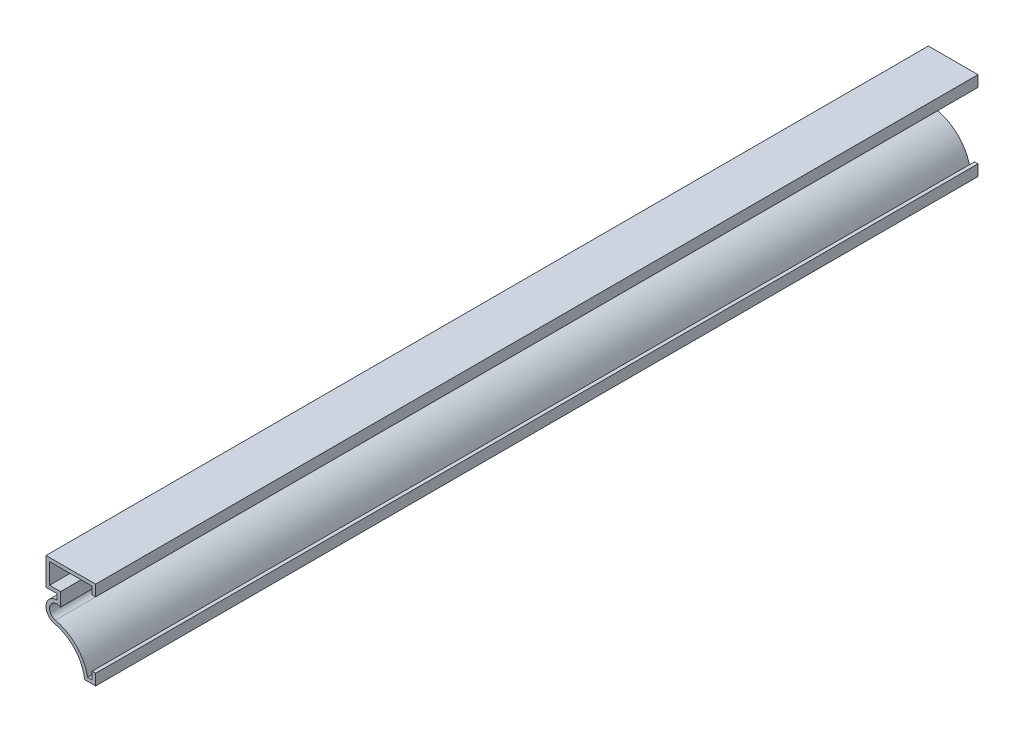
from build123d import *

# Parameters (mm, degrees)
EXTRUDE_THIN1_DEPTH = 254


with BuildPart() as part:
    # Sketch1 → Extrude-Thin1 (new body)
    with BuildSketch(Plane.XY):
        with BuildLine():
            Line((0, 22.225), (0, 25.4))
            Line((0, 25.4), (-14.2875, 25.4))
            Line((-14.2875, 25.4), (-14.2875, 17.4625))
            Line((-14.2875, 17.4625), (-11.1125, 17.4625))
            Line((-11.1125, 17.4625), (-11.1125, 15.875))
            ThreePointArc((-11.1125, 15.875), (-14.26780648, 13.053080749), (-11.814281402, 9.603529774))
            ThreePointArc((-11.814281402, 9.603529774), (-5.968853266, 6.174354687), (-3.175, 0))
            Line((-3.175, 0), (0, 0))
            Line((0, 0), (0, 3.175))
            Line((0, 3.175), (-1.016, 3.175))
            Line((-1.016, 3.175), (-1.016, 1.016))
            Line((-1.016, 1.016), (-2.305663985, 1.016))
            ThreePointArc((-2.305663985, 1.016), (-5.523409467, 7.185708972), (-11.589711354, 10.594400246))
            ThreePointArc((-11.589711354, 10.594400246), (-13.135814335, 13.453312752), (-10.0965, 14.605))
            Line((-10.0965, 14.605), (-10.0965, 18.4785))
            Line((-10.0965, 18.4785), (-13.2715, 18.4785))
            Line((-13.2715, 18.4785), (-13.2715, 24.384))
            Line((-13.2715, 24.384), (-1.016, 24.384))
            Line((-1.016, 24.384), (-1.016, 22.225))
            Line((-1.016, 22.225), (0, 22.225))
        make_face()
    extrude(amount=-EXTRUDE_THIN1_DEPTH)


solid = part.part
